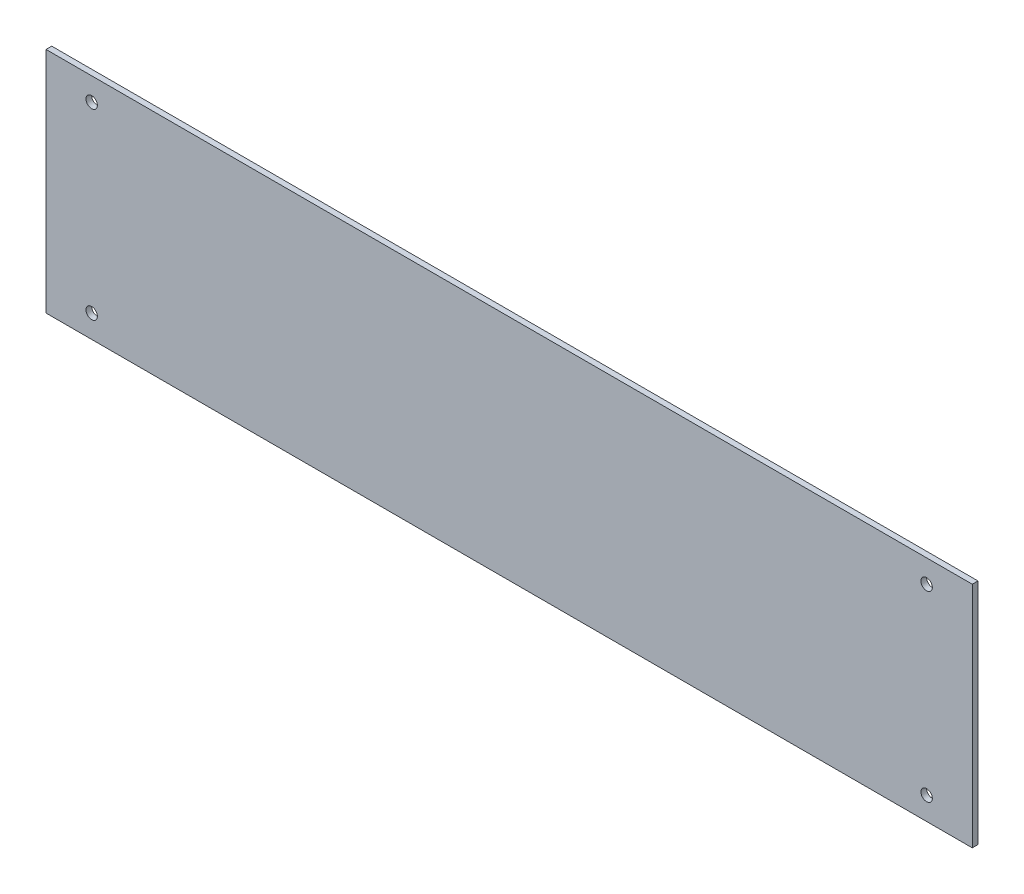
from build123d import *

# Parameters (mm, degrees)
SKETCH1_W           = 515.20598
SKETCH1_H           = 127
SKETCH1_R           = 3.175
BOSS_EXTRUDE1_DEPTH = 3.175


with BuildPart() as part:
    # Sketch1 → Boss-Extrude1 (new body)
    with BuildSketch(Plane.XY):
        Rectangle(SKETCH1_W, SKETCH1_H)
        with Locations((-232.20299, 50.8)):
            Circle(SKETCH1_R, mode=Mode.SUBTRACT)
        with Locations((-232.20299, -50.8)):
            Circle(SKETCH1_R, mode=Mode.SUBTRACT)
        with Locations((232.20299, -50.8)):
            Circle(SKETCH1_R, mode=Mode.SUBTRACT)
        with Locations((232.20299, 50.8)):
            Circle(SKETCH1_R, mode=Mode.SUBTRACT)
    extrude(amount=BOSS_EXTRUDE1_DEPTH)


solid = part.part
